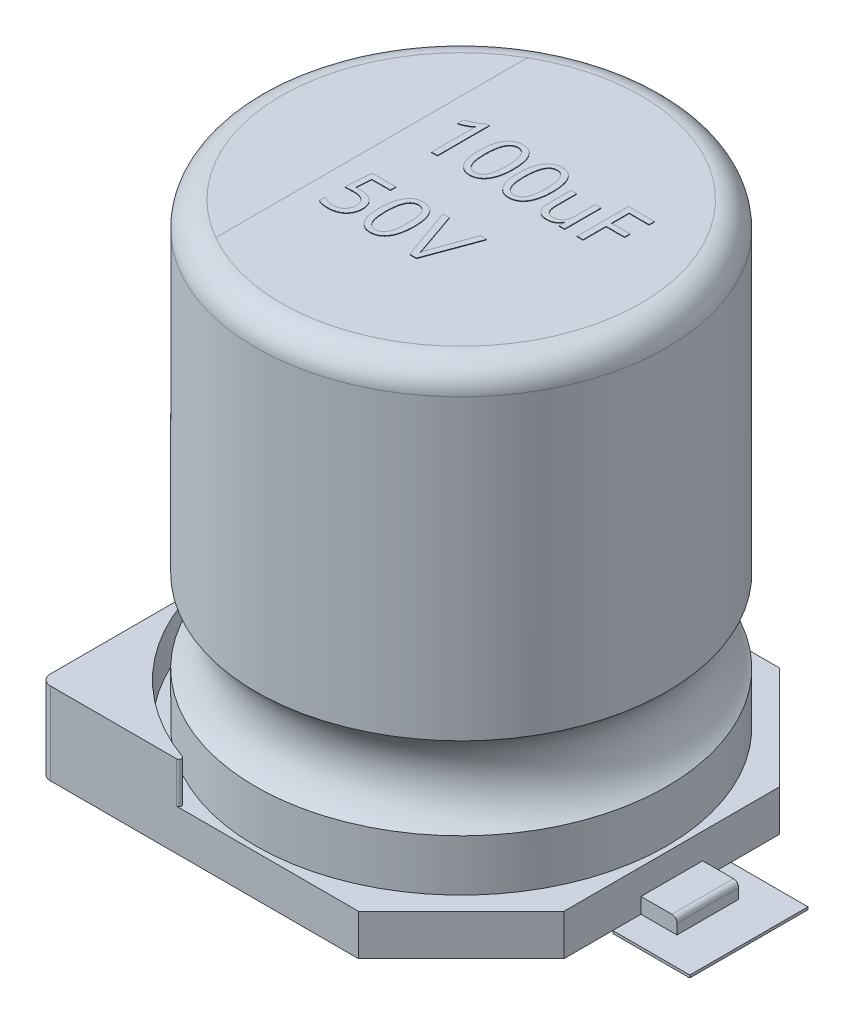
from build123d import *

# Parameters (mm, degrees)
SKETCH1_R             = 4
BOSS_EXTRUDE1_DEPTH   = 8.9
FILLET1_R             = 0.5
SKETCH3_W             = 8.2
SKETCH3_H             = 8.2
BOSS_EXTRUDE2_DEPTH   = 0.8
CHAMFER1_SIZE         = 2
BOSS_EXTRUDE3_DEPTH   = 0.8
FILLET2_R             = 0.05
SKETCH5_W             = 1.2
SKETCH5_H             = 0.3
BOSS_EXTRUDE4_DEPTH   = 0.7
FILLET3_R             = 0.1
FILLET4_R             = 0.2
BOSS_EXTRUDE5_DEPTH   = 0.01
SKETCH8_W             = 1.5
SKETCH8_H             = 2.3
BOSS_EXTRUDE6_DEPTH   = 0.05
BOSS_EXTRUDE6_2_DEPTH = 0.05


with BuildPart() as part:
    # Sketch1 → Boss-Extrude1 (new body)
    with BuildSketch(Plane(origin=(0, 0, 0), x_dir=(1, 0, 0), z_dir=(0, 1, 0))):
        with Locations(Location((0, 0, 0), (0, 0, 270))):
            Circle(SKETCH1_R)
    extrude(amount=BOSS_EXTRUDE1_DEPTH)

    # Sketch2 → Cut-Revolve1 (revolve, cut)
    with BuildSketch(Plane.XY, mode=Mode.PRIVATE) as cut_revolve1_sk:
        with BuildLine():
            Line((-4, 2.6), (-4, 1))
            ThreePointArc((-4, 1), (-3.6, 1.8), (-4, 2.6))
        make_face()
    revolve(cut_revolve1_sk.sketch.rotate(Axis((0, 0, 0), (0, 1, 0)), 270), axis=Axis((0, 0, 0), (0, 1, 0)), mode=Mode.SUBTRACT)

    # Fillet1
    fillet1_edges = [part.edges().sort_by_distance(p)[0] for p in [
        (0, 8.9, -4),
    ]]
    fillet(fillet1_edges, radius=FILLET1_R)

    # Sketch7 → Boss-Extrude5 (add)
    with BuildSketch(Plane(origin=(0, 8.9, 0), x_dir=(1, 0, 0), z_dir=(0, 1, 0))):
        with BuildLine():
            Line((-0.963431723, 0.500188603), (-1.07732975, 0.500188603))
            Line((-1.07732975, 0.500188603), (-1.07732975, 1.355040577))
            add(Edge.make_bspline(
                [(-1.07732975, 1.355040577), (-1.079777093, 1.352756928), (-1.085034792, 1.3478509), (-1.09387705, 1.340498161), (-1.104208441, 1.332640753), (-1.12049976, 1.321512017), (-1.14335142, 1.307312876), (-1.173085751, 1.290498318), (-1.20548104, 1.274747136), (-1.239040454, 1.259578397), (-1.273144639, 1.246529775), (-1.296298393, 1.240145156), (-1.307592907, 1.237030708)],
                knots=[0, 0, 0, 0, 0.385015468, 0.827139693, 1.322250538, 1.877706807, 3.096125656, 4.416274777, 5.805430079, 7.238282366, 8.652820666, 10, 10, 10, 10], degree=3))
            Line((-1.307592907, 1.237030708), (-1.307592907, 1.352162287))
            add(Edge.make_bspline(
                [(-1.307592907, 1.352162287), (-1.294653334, 1.35610978), (-1.267783898, 1.364306875), (-1.227473316, 1.380221553), (-1.186459456, 1.398993626), (-1.14575269, 1.419805536), (-1.106604769, 1.442327949), (-1.069663837, 1.465477943), (-1.036198144, 1.488813595), (-1.016101286, 1.505474617), (-1.006606065, 1.513346498)],
                knots=[0, 0, 0, 0, 0.94458981, 1.961470684, 3.023913207, 4.09427277, 5.153432408, 6.177318749, 7.138832524, 8, 8, 8, 8], degree=3))
            Line((-1.006606065, 1.513346498), (-0.963431723, 1.513346498))
            Line((-0.963431723, 1.513346498), (-0.963431723, 0.500188603))
        make_face()
        with BuildLine():
            add(Edge.make_bspline(
                [(0.005112685, 1.004711629), (0.004826131, 0.984557566), (0.004268968, 0.945370772), (0.00026028, 0.888304877), (-0.00697127, 0.834774088), (-0.01670279, 0.78474756), (-0.029197763, 0.738431643), (-0.044185511, 0.695758481), (-0.061768763, 0.65682236), (-0.081983566, 0.621736309), (-0.104311728, 0.590281443), (-0.129707187, 0.563262978), (-0.157079658, 0.539685765), (-0.187165811, 0.520517467), (-0.219425585, 0.505217818), (-0.254139435, 0.495007822), (-0.29072768, 0.488007663), (-0.315919286, 0.487360705), (-0.328768894, 0.487030708)],
                knots=[0, 0, 0, 0, 1.398980466, 2.720124312, 3.96812368, 5.146432578, 6.255415985, 7.295087503, 8.282879546, 9.216336252, 10.102253837, 10.953825877, 11.784043498, 12.603506409, 13.42284504, 14.253498671, 15.109153359, 16, 16, 16, 16], degree=3))
            add(Edge.make_bspline(
                [(-0.328768894, 0.487030708), (-0.340926926, 0.487403858), (-0.36472116, 0.488134142), (-0.399403608, 0.494513325), (-0.432131855, 0.504747043), (-0.462749696, 0.519260787), (-0.491170149, 0.537718507), (-0.517128174, 0.560078852), (-0.540797909, 0.586154425), (-0.562204288, 0.615858168), (-0.581056959, 0.649361911), (-0.597559877, 0.686395783), (-0.611358843, 0.727057537), (-0.623154052, 0.771117384), (-0.632024842, 0.818768253), (-0.638552103, 0.869693802), (-0.642510507, 0.923988105), (-0.642912284, 0.961256343), (-0.643119223, 0.980451761)],
                knots=[0, 0, 0, 0, 0.888155269, 1.738190458, 2.568434008, 3.38864091, 4.207101744, 5.03849325, 5.886044594, 6.7759361, 7.709272942, 8.69152049, 9.735599895, 10.845083744, 12.023162705, 13.27590253, 14.596923554, 16, 16, 16, 16], degree=3))
            add(Edge.make_bspline(
                [(-0.643119223, 0.980451761), (-0.642843557, 1.001497645), (-0.642307836, 1.042397677), (-0.638162264, 1.101825233), (-0.631477783, 1.157428823), (-0.622151233, 1.20925434), (-0.609844107, 1.257126333), (-0.595126484, 1.301093022), (-0.577891285, 1.341086758), (-0.557950963, 1.376997022), (-0.535517212, 1.40900922), (-0.510275956, 1.436746934), (-0.482599403, 1.460461121), (-0.452195954, 1.479788402), (-0.419394292, 1.49483533), (-0.384192765, 1.505504416), (-0.346852143, 1.512337738), (-0.321123895, 1.513005818), (-0.308004092, 1.513346498)],
                knots=[0, 0, 0, 0, 1.426258677, 2.771754592, 4.035124818, 5.220331935, 6.337825632, 7.382114204, 8.359741748, 9.284994213, 10.161296122, 11.002979272, 11.820109764, 12.624106341, 13.436709906, 14.257961594, 15.111668944, 16, 16, 16, 16], degree=3))
            add(Edge.make_bspline(
                [(-0.308004092, 1.513346498), (-0.295368868, 1.512959369), (-0.270705783, 1.512203721), (-0.23495184, 1.506094994), (-0.201540462, 1.496387059), (-0.170760666, 1.482139609), (-0.14236875, 1.464156343), (-0.116378867, 1.442121729), (-0.09317833, 1.415950319), (-0.072122691, 1.3860259), (-0.054102459, 1.351883719), (-0.03785807, 1.31408476), (-0.024755916, 1.272056949), (-0.013614383, 1.226276634), (-0.005386797, 1.176431001), (0.000747166, 1.12277945), (0.004461983, 1.065070853), (0.004890986, 1.025276442), (0.005112685, 1.004711629)],
                knots=[0, 0, 0, 0, 0.899241396, 1.755257189, 2.575108327, 3.369931066, 4.161902333, 4.96169813, 5.78762661, 6.645962214, 7.56082504, 8.531597655, 9.571777694, 10.691464586, 11.88443752, 13.166498411, 14.535713275, 16, 16, 16, 16], degree=3))
        make_face()
        with BuildLine():
            add(Edge.make_bspline(
                [(-0.111458039, 0.993198471), (-0.111635005, 1.010469562), (-0.111977861, 1.043930687), (-0.114064832, 1.092507874), (-0.118353658, 1.137667761), (-0.12339049, 1.179587018), (-0.13070288, 1.218050581), (-0.139128469, 1.253280964), (-0.149453536, 1.285169971), (-0.161197046, 1.313719893), (-0.174667974, 1.338955551), (-0.189638832, 1.360931968), (-0.206310236, 1.379614653), (-0.224648836, 1.394887973), (-0.244573932, 1.406866101), (-0.266277141, 1.414960968), (-0.289367294, 1.420441518), (-0.305366891, 1.42097051), (-0.313555079, 1.421241235)],
                knots=[0, 0, 0, 0, 1.581181307, 3.063391078, 4.449305256, 5.73327765, 6.92683892, 8.031533681, 9.047337031, 9.992258722, 10.853979057, 11.661441156, 12.421081853, 13.138403699, 13.838846326, 14.537910874, 15.251739941, 16, 16, 16, 16], degree=3))
            add(Edge.make_bspline(
                [(-0.313555079, 1.421241235), (-0.322149139, 1.420956637), (-0.339019139, 1.420397978), (-0.363407175, 1.415083426), (-0.386204613, 1.406638965), (-0.407231815, 1.394518687), (-0.426456861, 1.378867186), (-0.444102981, 1.359920592), (-0.459894199, 1.337502337), (-0.474045623, 1.311820005), (-0.486699712, 1.28281579), (-0.497086535, 1.250213365), (-0.506460167, 1.214429829), (-0.513622413, 1.175157744), (-0.519677256, 1.132653105), (-0.523608913, 1.086666414), (-0.526124054, 1.037292279), (-0.52640388, 1.003207366), (-0.5265485, 0.985591563)],
                knots=[0, 0, 0, 0, 0.764995805, 1.501674303, 2.212925961, 2.924256282, 3.65393935, 4.414460527, 5.224546987, 6.091227052, 7.023912083, 8.039810551, 9.137474513, 10.318540051, 11.595133009, 12.962565651, 14.430189818, 16, 16, 16, 16], degree=3))
            add(Edge.make_bspline(
                [(-0.5265485, 0.985591563), (-0.526402041, 0.969209241), (-0.526118139, 0.937452912), (-0.523614364, 0.891364271), (-0.519634554, 0.848405362), (-0.513809401, 0.808633363), (-0.506874679, 0.771954437), (-0.497741057, 0.738621381), (-0.487380411, 0.708264032), (-0.475039657, 0.681192385), (-0.461392387, 0.656982181), (-0.445580087, 0.636351776), (-0.428514073, 0.618478865), (-0.409363524, 0.604260881), (-0.388775468, 0.592951387), (-0.366538931, 0.58487104), (-0.342611158, 0.580072872), (-0.326118398, 0.579453407), (-0.317666921, 0.579135971)],
                knots=[0, 0, 0, 0, 1.543513286, 2.992024866, 4.347767877, 5.607075833, 6.778486024, 7.862468221, 8.861099137, 9.797386861, 10.662401359, 11.473455982, 12.240599663, 12.983190345, 13.711379138, 14.446775782, 15.204072658, 16, 16, 16, 16], degree=3))
            add(Edge.make_bspline(
                [(-0.317666921, 0.579135971), (-0.309354713, 0.579462603), (-0.293070777, 0.580102486), (-0.269360779, 0.584815964), (-0.247382033, 0.593201099), (-0.226927748, 0.604593384), (-0.208308613, 0.619420262), (-0.191318052, 0.637397511), (-0.175736559, 0.658496883), (-0.162459537, 0.683184252), (-0.150125444, 0.710733256), (-0.13984854, 0.741627939), (-0.130992629, 0.77569519), (-0.123969588, 0.813015594), (-0.118126249, 0.85347046), (-0.114459312, 0.897202574), (-0.111866128, 0.944099177), (-0.111597053, 0.976472965), (-0.111458039, 0.993198471)],
                knots=[0, 0, 0, 0, 0.775360401, 1.518961016, 2.243373551, 2.96192122, 3.694889719, 4.454670758, 5.264184671, 6.134259122, 7.064577354, 8.077594077, 9.167837551, 10.346585987, 11.618858978, 12.979815247, 14.439659868, 16, 16, 16, 16], degree=3))
        make_face(mode=Mode.SUBTRACT)
        with BuildLine():
            add(Edge.make_bspline(
                [(0.768270579, 1.004711629), (0.767984026, 0.984557566), (0.767426863, 0.945370772), (0.763418175, 0.888304877), (0.756186625, 0.834774088), (0.746455105, 0.78474756), (0.733960132, 0.738431643), (0.718972384, 0.695758481), (0.701389132, 0.65682236), (0.681174329, 0.621736309), (0.658846167, 0.590281443), (0.633450707, 0.563262978), (0.606078237, 0.539685765), (0.575992083, 0.520517467), (0.54373231, 0.505217818), (0.50901846, 0.495007822), (0.472430214, 0.488007663), (0.447238608, 0.487360705), (0.434389, 0.487030708)],
                knots=[0, 0, 0, 0, 1.398980466, 2.720124312, 3.96812368, 5.146432578, 6.255415985, 7.295087503, 8.282879546, 9.216336252, 10.102253837, 10.953825877, 11.784043498, 12.603506409, 13.42284504, 14.253498671, 15.109153359, 16, 16, 16, 16], degree=3))
            add(Edge.make_bspline(
                [(0.434389, 0.487030708), (0.422230969, 0.487403858), (0.398436735, 0.488134142), (0.363754287, 0.494513325), (0.331026039, 0.504747043), (0.300408199, 0.519260787), (0.271987746, 0.537718507), (0.246029721, 0.560078852), (0.222359986, 0.586154425), (0.200953607, 0.615858168), (0.182100935, 0.649361911), (0.165598018, 0.686395783), (0.151799052, 0.727057537), (0.140003843, 0.771117384), (0.131133053, 0.818768253), (0.124605791, 0.869693802), (0.120647388, 0.923988105), (0.120245611, 0.961256343), (0.120038671, 0.980451761)],
                knots=[0, 0, 0, 0, 0.888155269, 1.738190458, 2.568434008, 3.38864091, 4.207101744, 5.03849325, 5.886044594, 6.7759361, 7.709272942, 8.69152049, 9.735599895, 10.845083744, 12.023162705, 13.27590253, 14.596923554, 16, 16, 16, 16], degree=3))
            add(Edge.make_bspline(
                [(0.120038671, 0.980451761), (0.120314337, 1.001497645), (0.120850059, 1.042397677), (0.124995631, 1.101825233), (0.131680111, 1.157428823), (0.141006661, 1.20925434), (0.153313788, 1.257126333), (0.168031411, 1.301093022), (0.18526661, 1.341086758), (0.205206931, 1.376997022), (0.227640682, 1.40900922), (0.252881939, 1.436746934), (0.280558491, 1.460461121), (0.31096194, 1.479788402), (0.343763603, 1.49483533), (0.37896513, 1.505504416), (0.416305751, 1.512337738), (0.442033999, 1.513005818), (0.455153803, 1.513346498)],
                knots=[0, 0, 0, 0, 1.426258677, 2.771754592, 4.035124818, 5.220331935, 6.337825632, 7.382114204, 8.359741748, 9.284994213, 10.161296122, 11.002979272, 11.820109764, 12.624106341, 13.436709906, 14.257961594, 15.111668944, 16, 16, 16, 16], degree=3))
            add(Edge.make_bspline(
                [(0.455153803, 1.513346498), (0.467789027, 1.512959369), (0.492452111, 1.512203721), (0.528206054, 1.506094994), (0.561617433, 1.496387059), (0.592397229, 1.482139609), (0.620789145, 1.464156343), (0.646779028, 1.442121729), (0.669979565, 1.415950319), (0.691035204, 1.3860259), (0.709055435, 1.351883719), (0.725299825, 1.31408476), (0.738401979, 1.272056949), (0.749543511, 1.226276634), (0.757771097, 1.176431001), (0.763905061, 1.12277945), (0.767619878, 1.065070853), (0.768048881, 1.025276442), (0.768270579, 1.004711629)],
                knots=[0, 0, 0, 0, 0.899241396, 1.755257189, 2.575108327, 3.369931066, 4.161902333, 4.96169813, 5.78762661, 6.645962214, 7.56082504, 8.531597655, 9.571777694, 10.691464586, 11.88443752, 13.166498411, 14.535713275, 16, 16, 16, 16], degree=3))
        make_face()
        with BuildLine():
            add(Edge.make_bspline(
                [(0.651699856, 0.993198471), (0.651522889, 1.010469562), (0.651180034, 1.043930687), (0.649093063, 1.092507874), (0.644804237, 1.137667761), (0.639767405, 1.179587018), (0.632455014, 1.218050581), (0.624029426, 1.253280964), (0.613704359, 1.285169971), (0.601960849, 1.313719893), (0.588489921, 1.338955551), (0.573519063, 1.360931968), (0.556847658, 1.379614653), (0.538509059, 1.394887973), (0.518583963, 1.406866101), (0.496880754, 1.414960968), (0.473790601, 1.420441518), (0.457791004, 1.42097051), (0.449602816, 1.421241235)],
                knots=[0, 0, 0, 0, 1.581181307, 3.063391078, 4.449305256, 5.73327765, 6.92683892, 8.031533681, 9.047337031, 9.992258722, 10.853979057, 11.661441156, 12.421081853, 13.138403699, 13.838846326, 14.537910874, 15.251739941, 16, 16, 16, 16], degree=3))
            add(Edge.make_bspline(
                [(0.449602816, 1.421241235), (0.441008756, 1.420956637), (0.424138756, 1.420397978), (0.39975072, 1.415083426), (0.376953282, 1.406638965), (0.35592608, 1.394518687), (0.336701034, 1.378867186), (0.319054913, 1.359920592), (0.303263696, 1.337502337), (0.289112272, 1.311820005), (0.276458182, 1.28281579), (0.26607136, 1.250213365), (0.256697728, 1.214429829), (0.249535481, 1.175157744), (0.243480639, 1.132653105), (0.239548982, 1.086666414), (0.23703384, 1.037292279), (0.236754015, 1.003207366), (0.236609395, 0.985591563)],
                knots=[0, 0, 0, 0, 0.764995805, 1.501674303, 2.212925961, 2.924256282, 3.65393935, 4.414460527, 5.224546987, 6.091227052, 7.023912083, 8.039810551, 9.137474513, 10.318540051, 11.595133009, 12.962565651, 14.430189818, 16, 16, 16, 16], degree=3))
            add(Edge.make_bspline(
                [(0.236609395, 0.985591563), (0.236755854, 0.969209241), (0.237039756, 0.937452912), (0.239543531, 0.891364271), (0.243523341, 0.848405362), (0.249348493, 0.808633363), (0.256283216, 0.771954437), (0.265416837, 0.738621381), (0.275777484, 0.708264032), (0.288118237, 0.681192385), (0.301765507, 0.656982181), (0.317577808, 0.636351776), (0.334643822, 0.618478865), (0.35379437, 0.604260881), (0.374382427, 0.592951387), (0.396618963, 0.58487104), (0.420546736, 0.580072872), (0.437039497, 0.579453407), (0.445490974, 0.579135971)],
                knots=[0, 0, 0, 0, 1.543513286, 2.992024866, 4.347767877, 5.607075833, 6.778486024, 7.862468221, 8.861099137, 9.797386861, 10.662401359, 11.473455982, 12.240599663, 12.983190345, 13.711379138, 14.446775782, 15.204072658, 16, 16, 16, 16], degree=3))
            add(Edge.make_bspline(
                [(0.445490974, 0.579135971), (0.453803181, 0.579462603), (0.470087117, 0.580102486), (0.493797116, 0.584815964), (0.515775862, 0.593201099), (0.536230147, 0.604593384), (0.554849281, 0.619420262), (0.571839842, 0.637397511), (0.587421335, 0.658496883), (0.600698358, 0.683184252), (0.61303245, 0.710733256), (0.623309355, 0.741627939), (0.632165265, 0.77569519), (0.639188306, 0.813015594), (0.645031646, 0.85347046), (0.648698582, 0.897202574), (0.651291767, 0.944099177), (0.651560842, 0.976472965), (0.651699856, 0.993198471)],
                knots=[0, 0, 0, 0, 0.775360401, 1.518961016, 2.243373551, 2.96192122, 3.694889719, 4.454670758, 5.264184671, 6.134259122, 7.064577354, 8.077594077, 9.167837551, 10.346585987, 11.618858978, 12.979815247, 14.439659868, 16, 16, 16, 16], degree=3))
        make_face(mode=Mode.SUBTRACT)
        with BuildLine():
            Line((1.513336369, 0.500188603), (1.399438343, 0.500188603))
            Line((1.399438343, 0.500188603), (1.399438343, 0.612441892))
            Line((1.399438343, 0.612441892), (1.396765645, 0.612441892))
            add(Edge.make_bspline(
                [(1.396765645, 0.612441892), (1.390720663, 0.602460299), (1.378922171, 0.5829784), (1.357224617, 0.557406109), (1.333497285, 0.535340747), (1.30679844, 0.517874984), (1.27796377, 0.503876254), (1.246605155, 0.493991312), (1.212766798, 0.488233325), (1.189414343, 0.487439271), (1.177398869, 0.487030708)],
                knots=[0, 0, 0, 0, 1.050691007, 2.050720406, 3.012962404, 3.962401766, 4.915874185, 5.894932476, 6.916885468, 8, 8, 8, 8], degree=3))
            add(Edge.make_bspline(
                [(1.177398869, 0.487030708), (1.167106673, 0.487257871), (1.147213655, 0.487696936), (1.11834269, 0.491353296), (1.091359331, 0.496789144), (1.066537263, 0.505487129), (1.043447569, 0.515877394), (1.022427463, 0.528850187), (1.003437756, 0.544280218), (0.986572548, 0.56212546), (0.971356904, 0.582119485), (0.958722421, 0.604808693), (0.947754222, 0.629646774), (0.938794621, 0.656780083), (0.931760999, 0.68627913), (0.926955997, 0.718120739), (0.92409119, 0.75232886), (0.923696159, 0.775881872), (0.923492619, 0.78801755)],
                knots=[0, 0, 0, 0, 1.09540131, 2.117219514, 3.094696566, 4.020015321, 4.911365501, 5.786165053, 6.642013186, 7.509079247, 8.394916856, 9.30993597, 10.267157936, 11.282441873, 12.347880503, 13.49236844, 14.707944063, 16, 16, 16, 16], degree=3))
            Line((0.923492619, 0.78801755), (0.923492619, 1.210714919))
            Line((0.923492619, 1.210714919), (1.036568277, 1.210714919))
            Line((1.036568277, 1.210714919), (1.036568277, 0.804053735))
            add(Edge.make_bspline(
                [(1.036568277, 0.804053735), (1.036658129, 0.79500285), (1.03683264, 0.777424219), (1.038994686, 0.751898193), (1.042143232, 0.72804247), (1.046826816, 0.705955212), (1.053044542, 0.68569587), (1.060388214, 0.66715835), (1.068975395, 0.650310847), (1.079241694, 0.635355566), (1.090611126, 0.621958112), (1.103608072, 0.610479502), (1.117877537, 0.600820717), (1.133413594, 0.592673278), (1.150370126, 0.586537416), (1.168663857, 0.582288295), (1.188210634, 0.579518344), (1.201717402, 0.57926565), (1.208648869, 0.579135971)],
                knots=[0, 0, 0, 0, 1.343703186, 2.609740898, 3.801442941, 4.915248641, 5.95827345, 6.944754588, 7.873313373, 8.759642607, 9.632786239, 10.476245362, 11.325882859, 12.18618061, 13.074785555, 13.995503533, 14.971323121, 16, 16, 16, 16], degree=3))
            add(Edge.make_bspline(
                [(1.208648869, 0.579135971), (1.215444264, 0.579340895), (1.228822529, 0.579744332), (1.248382544, 0.582703586), (1.267049545, 0.587339775), (1.284654366, 0.594262065), (1.301392063, 0.602948489), (1.317350699, 0.613434023), (1.332147143, 0.626102121), (1.345940795, 0.640486012), (1.358314303, 0.656498858), (1.369603949, 0.673539607), (1.378805849, 0.692024015), (1.38648315, 0.711539654), (1.39212846, 0.732324927), (1.396555207, 0.754141181), (1.398974255, 0.77727204), (1.39928124, 0.793083669), (1.399438343, 0.801175445)],
                knots=[0, 0, 0, 0, 0.99348202, 1.955893163, 2.886897847, 3.800751478, 4.715209456, 5.640858053, 6.586634716, 7.557773505, 8.550193329, 9.542613152, 10.542143211, 11.563936364, 12.604722674, 13.687744657, 14.816677783, 16, 16, 16, 16], degree=3))
            Line((1.399438343, 0.801175445), (1.399438343, 1.210714919))
            Line((1.399438343, 1.210714919), (1.513336369, 1.210714919))
            Line((1.513336369, 1.210714919), (1.513336369, 0.500188603))
        make_face()
        Polygon((2.261897224, 1.394925445), (1.873328145, 1.394925445), (1.873328145, 1.052820182), (2.232703145, 1.052820182), (2.232703145, 0.947557024), (1.873328145, 0.947557024), (1.873328145, 0.500188603), (1.756757421, 0.500188603), (1.756757421, 1.500188603), (2.261897224, 1.500188603), align=None)
        with BuildLine():
            add(Edge.make_bspline(
                [(-0.793612644, -1.127775788), (-0.793960298, -1.139574748), (-0.794642043, -1.162712395), (-0.799064628, -1.196669956), (-0.807223545, -1.228776685), (-0.818031971, -1.259148157), (-0.831964387, -1.287475253), (-0.84837346, -1.313832799), (-0.867512243, -1.338196132), (-0.889334264, -1.360347166), (-0.913582321, -1.380386349), (-0.94053288, -1.397725884), (-0.969631482, -1.413005561), (-1.001266549, -1.425393112), (-1.034752556, -1.435646199), (-1.070265746, -1.44238049), (-1.107502327, -1.4469306), (-1.132962205, -1.447424321), (-1.145997513, -1.447677104)],
                knots=[0, 0, 0, 0, 1.056864167, 2.072500419, 3.059485391, 4.018613275, 4.954681828, 5.881162702, 6.794724112, 7.723560484, 8.661137091, 9.605998599, 10.588833302, 11.59982216, 12.644532083, 13.720683555, 14.833003331, 16, 16, 16, 16], degree=3))
            add(Edge.make_bspline(
                [(-1.145997513, -1.447677104), (-1.157169676, -1.44755688), (-1.178844942, -1.447323631), (-1.210217715, -1.445589255), (-1.239346016, -1.442162006), (-1.266312612, -1.438066715), (-1.291036625, -1.432285861), (-1.313517302, -1.425324282), (-1.333853616, -1.417259251), (-1.346100363, -1.410454138), (-1.352000802, -1.407175459)],
                knots=[0, 0, 0, 0, 1.263126396, 2.450608766, 3.550077914, 4.578015321, 5.532741343, 6.41739748, 7.237507678, 8, 8, 8, 8], degree=3))
            Line((-1.352000802, -1.407175459), (-1.352000802, -1.289782367))
            add(Edge.make_bspline(
                [(-1.352000802, -1.289782367), (-1.343644519, -1.295047632), (-1.327115968, -1.305462213), (-1.301398701, -1.318689721), (-1.275672137, -1.330073303), (-1.249798347, -1.339444348), (-1.223733025, -1.346605094), (-1.1974887, -1.351776104), (-1.171090993, -1.354979568), (-1.153407625, -1.355374304), (-1.144558368, -1.35557184)],
                knots=[0, 0, 0, 0, 1.073575538, 2.123509434, 3.141212585, 4.131255582, 5.1129617, 6.077547705, 7.037950563, 8, 8, 8, 8], degree=3))
            add(Edge.make_bspline(
                [(-1.144558368, -1.35557184), (-1.13577573, -1.355388981), (-1.118565534, -1.355030654), (-1.09348191, -1.351802344), (-1.069600723, -1.347029456), (-1.047197078, -1.339744061), (-1.026294475, -1.330749682), (-1.00693468, -1.320167604), (-0.989181315, -1.308039635), (-0.973029778, -1.29419492), (-0.958648025, -1.278678747), (-0.94576485, -1.261858724), (-0.93509558, -1.243311522), (-0.926051079, -1.223573267), (-0.918714709, -1.20255171), (-0.914035937, -1.180358364), (-0.910707996, -1.157275006), (-0.910360819, -1.141563111), (-0.910183368, -1.133532367)],
                knots=[0, 0, 0, 0, 1.158660806, 2.270477318, 3.333079092, 4.368579658, 5.373363954, 6.332745853, 7.27608927, 8.206156569, 9.134110276, 10.063957633, 10.99630925, 11.951503368, 12.926911662, 13.927616427, 14.940752784, 16, 16, 16, 16], degree=3))
            add(Edge.make_bspline(
                [(-0.910183368, -1.133532367), (-0.910372696, -1.125504516), (-0.91074311, -1.109798279), (-0.913878157, -1.086857782), (-0.919040275, -1.065263813), (-0.925899626, -1.044864207), (-0.935384798, -1.026114831), (-0.9463914, -1.008384945), (-0.960003861, -0.992409341), (-0.97515884, -0.977427808), (-0.992551618, -0.964366436), (-1.011647661, -0.952710772), (-1.032630564, -0.942803068), (-1.055603774, -0.9351487), (-1.080270122, -0.928920598), (-1.106733846, -0.924473626), (-1.135111939, -0.921743454), (-1.154625896, -0.921491479), (-1.164706394, -0.921361314)],
                knots=[0, 0, 0, 0, 1.024220939, 2.003855773, 2.947861307, 3.855091956, 4.742976808, 5.623725423, 6.511739495, 7.414744547, 8.338353125, 9.280330718, 10.266270024, 11.292393647, 12.365736532, 13.510265708, 14.713855882, 16, 16, 16, 16], degree=3))
            add(Edge.make_bspline(
                [(-1.164706394, -0.921361314), (-1.171560192, -0.921394443), (-1.185681562, -0.921462702), (-1.207193389, -0.922254008), (-1.229272396, -0.922665261), (-1.25139504, -0.923887785), (-1.27327405, -0.924724478), (-1.294443985, -0.926244892), (-1.314396907, -0.92779629), (-1.327195143, -0.929147098), (-1.333291921, -0.92979059)],
                knots=[0, 0, 0, 0, 0.974070636, 2.006947305, 3.059296761, 4.112367188, 5.155707916, 6.170982707, 7.128699404, 8, 8, 8, 8], degree=3))
            Line((-1.333291921, -0.92979059), (-1.299369223, -0.434519209))
            Line((-1.299369223, -0.434519209), (-0.839254092, -0.434519209))
            Line((-0.839254092, -0.434519209), (-0.839254092, -0.539782367))
            Line((-0.839254092, -0.539782367), (-1.200890605, -0.539782367))
            Line((-1.200890605, -0.539782367), (-1.221038631, -0.832751117))
            add(Edge.make_bspline(
                [(-1.221038631, -0.832751117), (-1.213433803, -0.832230981), (-1.197753352, -0.831158508), (-1.174165049, -0.830322134), (-1.151213288, -0.829335855), (-1.13633566, -0.829281563), (-1.129344552, -0.829256051)],
                knots=[0, 0, 0, 0, 0.996597619, 2.054892104, 3.085979286, 4, 4, 4, 4], degree=3))
            add(Edge.make_bspline(
                [(-1.129344552, -0.829256051), (-1.116519915, -0.829471408), (-1.091424837, -0.829892817), (-1.054899457, -0.83379702), (-1.020478392, -0.840447124), (-0.98815701, -0.849354217), (-0.958105906, -0.860993658), (-0.930105297, -0.874409082), (-0.904774709, -0.890581171), (-0.881781042, -0.908719161), (-0.861256526, -0.929021564), (-0.843194455, -0.95146848), (-0.828236963, -0.976424175), (-0.815624804, -1.003198072), (-0.805826391, -1.031899989), (-0.798506648, -1.0622926), (-0.794472337, -1.094497952), (-0.793903264, -1.116526179), (-0.793612644, -1.127775788)],
                knots=[0, 0, 0, 0, 1.209722839, 2.367169476, 3.460249484, 4.51448871, 5.52555128, 6.497162283, 7.438882481, 8.354766373, 9.255461188, 10.15719975, 11.065382765, 11.993869493, 12.944690782, 13.921729643, 14.938646801, 16, 16, 16, 16], degree=3))
        make_face()
        with BuildLine():
            add(Edge.make_bspline(
                [(0.005112685, -0.929996183), (0.004826131, -0.950150246), (0.004268968, -0.98933704), (0.00026028, -1.046402935), (-0.00697127, -1.099933724), (-0.01670279, -1.149960252), (-0.029197763, -1.196276169), (-0.044185511, -1.238949331), (-0.061768763, -1.277885452), (-0.081983566, -1.312971503), (-0.104311728, -1.344426369), (-0.129707187, -1.371444834), (-0.157079658, -1.395022046), (-0.187165811, -1.414190345), (-0.219425585, -1.429489994), (-0.254139435, -1.43969999), (-0.29072768, -1.446700149), (-0.315919286, -1.447347107), (-0.328768894, -1.447677104)],
                knots=[0, 0, 0, 0, 1.398980466, 2.720124312, 3.96812368, 5.146432578, 6.255415985, 7.295087503, 8.282879546, 9.216336252, 10.102253837, 10.953825877, 11.784043498, 12.603506409, 13.42284504, 14.253498671, 15.109153359, 16, 16, 16, 16], degree=3))
            add(Edge.make_bspline(
                [(-0.328768894, -1.447677104), (-0.340926926, -1.447303954), (-0.36472116, -1.44657367), (-0.399403608, -1.440194487), (-0.432131855, -1.429960769), (-0.462749696, -1.415447025), (-0.491170149, -1.396989305), (-0.517128174, -1.37462896), (-0.540797909, -1.348553387), (-0.562204288, -1.318849644), (-0.581056959, -1.285345901), (-0.597559877, -1.248312029), (-0.611358843, -1.207650274), (-0.623154052, -1.163590428), (-0.632024842, -1.115939559), (-0.638552103, -1.06501401), (-0.642510507, -1.010719707), (-0.642912284, -0.973451468), (-0.643119223, -0.954256051)],
                knots=[0, 0, 0, 0, 0.888155269, 1.738190458, 2.568434008, 3.38864091, 4.207101744, 5.03849325, 5.886044594, 6.7759361, 7.709272942, 8.69152049, 9.735599895, 10.845083744, 12.023162705, 13.27590253, 14.596923554, 16, 16, 16, 16], degree=3))
            add(Edge.make_bspline(
                [(-0.643119223, -0.954256051), (-0.642843557, -0.933210167), (-0.642307836, -0.892310135), (-0.638162264, -0.832882579), (-0.631477783, -0.777278988), (-0.622151233, -0.725453472), (-0.609844107, -0.677581479), (-0.595126484, -0.63361479), (-0.577891285, -0.593621054), (-0.557950963, -0.55771079), (-0.535517212, -0.525698592), (-0.510275956, -0.497960878), (-0.482599403, -0.47424669), (-0.452195954, -0.45491941), (-0.419394292, -0.439872482), (-0.384192765, -0.429203396), (-0.346852143, -0.422370074), (-0.321123895, -0.421701993), (-0.308004092, -0.421361314)],
                knots=[0, 0, 0, 0, 1.426258677, 2.771754592, 4.035124818, 5.220331935, 6.337825632, 7.382114204, 8.359741748, 9.284994213, 10.161296122, 11.002979272, 11.820109764, 12.624106341, 13.436709906, 14.257961594, 15.111668944, 16, 16, 16, 16], degree=3))
            add(Edge.make_bspline(
                [(-0.308004092, -0.421361314), (-0.295368868, -0.421748443), (-0.270705783, -0.422504091), (-0.23495184, -0.428612818), (-0.201540462, -0.438320753), (-0.170760666, -0.452568203), (-0.14236875, -0.470551469), (-0.116378867, -0.492586082), (-0.09317833, -0.518757492), (-0.072122691, -0.548681912), (-0.054102459, -0.582824092), (-0.03785807, -0.620623051), (-0.024755916, -0.662650863), (-0.013614383, -0.708431178), (-0.005386797, -0.75827681), (0.000747166, -0.811928362), (0.004461983, -0.869636959), (0.004890986, -0.90943137), (0.005112685, -0.929996183)],
                knots=[0, 0, 0, 0, 0.899241396, 1.755257189, 2.575108327, 3.369931066, 4.161902333, 4.96169813, 5.78762661, 6.645962214, 7.56082504, 8.531597655, 9.571777694, 10.691464586, 11.88443752, 13.166498411, 14.535713275, 16, 16, 16, 16], degree=3))
        make_face()
        with BuildLine():
            add(Edge.make_bspline(
                [(-0.111458039, -0.94150934), (-0.111635005, -0.92423825), (-0.111977861, -0.890777124), (-0.114064832, -0.842199937), (-0.118353658, -0.797040051), (-0.12339049, -0.755120794), (-0.13070288, -0.716657231), (-0.139128469, -0.681426848), (-0.149453536, -0.649537841), (-0.161197046, -0.620987919), (-0.174667974, -0.595752261), (-0.189638832, -0.573775843), (-0.206310236, -0.555093158), (-0.224648836, -0.539819839), (-0.244573932, -0.527841711), (-0.266277141, -0.519746844), (-0.289367294, -0.514266294), (-0.305366891, -0.513737302), (-0.313555079, -0.513466577)],
                knots=[0, 0, 0, 0, 1.581181307, 3.063391078, 4.449305256, 5.73327765, 6.92683892, 8.031533681, 9.047337031, 9.992258722, 10.853979057, 11.661441156, 12.421081853, 13.138403699, 13.838846326, 14.537910874, 15.251739941, 16, 16, 16, 16], degree=3))
            add(Edge.make_bspline(
                [(-0.313555079, -0.513466577), (-0.322149139, -0.513751174), (-0.339019139, -0.514309834), (-0.363407175, -0.519624386), (-0.386204613, -0.528068847), (-0.407231815, -0.540189125), (-0.426456861, -0.555840626), (-0.444102981, -0.57478722), (-0.459894199, -0.597205475), (-0.474045623, -0.622887807), (-0.486699712, -0.651892022), (-0.497086535, -0.684494447), (-0.506460167, -0.720277983), (-0.513622413, -0.759550068), (-0.519677256, -0.802054707), (-0.523608913, -0.848041398), (-0.526124054, -0.897415533), (-0.52640388, -0.931500446), (-0.5265485, -0.949116248)],
                knots=[0, 0, 0, 0, 0.764995805, 1.501674303, 2.212925961, 2.924256282, 3.65393935, 4.414460527, 5.224546987, 6.091227052, 7.023912083, 8.039810551, 9.137474513, 10.318540051, 11.595133009, 12.962565651, 14.430189818, 16, 16, 16, 16], degree=3))
            add(Edge.make_bspline(
                [(-0.5265485, -0.949116248), (-0.526402041, -0.965498571), (-0.526118139, -0.9972549), (-0.523614364, -1.043343541), (-0.519634554, -1.08630245), (-0.513809401, -1.126074449), (-0.506874679, -1.162753375), (-0.497741057, -1.196086431), (-0.487380411, -1.22644378), (-0.475039657, -1.253515427), (-0.461392387, -1.277725631), (-0.445580087, -1.298356036), (-0.428514073, -1.316228946), (-0.409363524, -1.330446931), (-0.388775468, -1.341756424), (-0.366538931, -1.349836772), (-0.342611158, -1.35463494), (-0.326118398, -1.355254405), (-0.317666921, -1.35557184)],
                knots=[0, 0, 0, 0, 1.543513286, 2.992024866, 4.347767877, 5.607075833, 6.778486024, 7.862468221, 8.861099137, 9.797386861, 10.662401359, 11.473455982, 12.240599663, 12.983190345, 13.711379138, 14.446775782, 15.204072658, 16, 16, 16, 16], degree=3))
            add(Edge.make_bspline(
                [(-0.317666921, -1.35557184), (-0.309354713, -1.355245209), (-0.293070777, -1.354605326), (-0.269360779, -1.349891848), (-0.247382033, -1.341506713), (-0.226927748, -1.330114428), (-0.208308613, -1.31528755), (-0.191318052, -1.297310301), (-0.175736559, -1.276210929), (-0.162459537, -1.25152356), (-0.150125444, -1.223974556), (-0.13984854, -1.193079873), (-0.130992629, -1.159012622), (-0.123969588, -1.121692217), (-0.118126249, -1.081237352), (-0.114459312, -1.037505238), (-0.111866128, -0.990608635), (-0.111597053, -0.958234847), (-0.111458039, -0.94150934)],
                knots=[0, 0, 0, 0, 0.775360401, 1.518961016, 2.243373551, 2.96192122, 3.694889719, 4.454670758, 5.264184671, 6.134259122, 7.064577354, 8.077594077, 9.167837551, 10.346585987, 11.618858978, 12.979815247, 14.439659868, 16, 16, 16, 16], degree=3))
        make_face(mode=Mode.SUBTRACT)
        with BuildLine():
            Line((0.93048275, -0.434519209), (0.562061698, -1.434519209))
            Line((0.562061698, -1.434519209), (0.433772224, -1.434519209))
            Line((0.433772224, -1.434519209), (0.072958079, -0.434519209))
            Line((0.072958079, -0.434519209), (0.202686698, -0.434519209))
            Line((0.202686698, -0.434519209), (0.478180119, -1.227282367))
            add(Edge.make_bspline(
                [(0.478180119, -1.227282367), (0.480292487, -1.233912657), (0.48464027, -1.247559459), (0.490253492, -1.26899756), (0.494618629, -1.291975053), (0.497072805, -1.307798624), (0.498328145, -1.315892564)],
                knots=[0, 0, 0, 0, 0.917522195, 1.888491001, 2.919938635, 4, 4, 4, 4], degree=3))
            Line((0.498328145, -1.315892564), (0.501000843, -1.315892564))
            add(Edge.make_bspline(
                [(0.501000843, -1.315892564), (0.502053286, -1.308743424), (0.504203131, -1.294139758), (0.509683649, -1.272075225), (0.515798621, -1.249046887), (0.521244423, -1.233690261), (0.524027158, -1.225843222)],
                knots=[0, 0, 0, 0, 0.930702889, 1.901162278, 2.927520758, 4, 4, 4, 4], degree=3))
            Line((0.524027158, -1.225843222), (0.804865974, -0.434519209))
            Line((0.804865974, -0.434519209), (0.93048275, -0.434519209))
        make_face()
    extrude(amount=BOSS_EXTRUDE5_DEPTH)


with BuildPart() as body_2:
    # Sketch3 → Boss-Extrude2 (new body)
    with BuildSketch(Plane.XZ):
        Rectangle(SKETCH3_W, SKETCH3_H)
    extrude(amount=BOSS_EXTRUDE2_DEPTH)

    # Chamfer1
    chamfer1_edges = [body_2.edges().sort_by_distance(p)[0] for p in [
        (4.1, -0.4, 4.1),
        (4.1, -0.4, -4.1),
    ]]
    chamfer(chamfer1_edges, length=CHAMFER1_SIZE)

    # Sketch4 → Boss-Extrude3 (add)
    with BuildSketch(Plane(origin=(0, 0, 0), x_dir=(1, 0, 0), z_dir=(0, 1, 0))):
        with BuildLine():
            Line((-1.119151464, -4.1), (-4.1, -4.1))
            Line((-4.1, -4.1), (-4.1, -1.119151464))
            ThreePointArc((-4.1, -1.119151464), (-3.00520382, -3.00520382), (-1.119151464, -4.1))
        make_face()
        with BuildLine():
            Line((-4.1, 4.1), (-1.119151464, 4.1))
            ThreePointArc((-1.119151464, 4.1), (-3.00520382, 3.00520382), (-4.1, 1.119151464))
            Line((-4.1, 1.119151464), (-4.1, 4.1))
        make_face()
    extrude(amount=BOSS_EXTRUDE3_DEPTH)

    # Fillet2
    fillet2_edges = [body_2.edges().sort_by_distance(p)[0] for p in [
        (-4.1, 0.4, -1.119151464),
        (-1.119151464, 0.4, -4.1),
        (-4.1, 0.4, 1.119151464),
        (-1.119151464, 0.4, 4.1),
    ]]
    fillet(fillet2_edges, radius=FILLET2_R)

    # Fillet4
    fillet4_edges = [body_2.edges().sort_by_distance(p)[0] for p in [
        (-4.1, 0, 4.1),
        (-4.1, 0, -4.1),
    ]]
    fillet(fillet4_edges, radius=FILLET4_R)


with BuildPart() as body_3:
    # Sketch5 → Boss-Extrude4 (new body)
    with BuildSketch(Plane.ZY.offset(4.1)):
        with Locations((0, -0.65)):
            Rectangle(SKETCH5_W, SKETCH5_H)
    extrude(amount=BOSS_EXTRUDE4_DEPTH)

    # Fillet3
    fillet3_edges = [body_3.edges().sort_by_distance(p)[0] for p in [
        (-4.8, -0.5, 0),
    ]]
    fillet(fillet3_edges, radius=FILLET3_R)


with BuildPart() as body_4:
    # Mirror3: mirrored copy
    add(body_3.part.mirror(Plane(origin=(0, 0, 0), x_dir=(0, 0, 1), z_dir=(1, 0, 0))))


with BuildPart() as body_5:
    # Sketch8 → Boss-Extrude6 (new body)
    with BuildSketch(Plane.XZ.offset(0.8)):
        with Locations((-4.85, 0)):
            Rectangle(SKETCH8_W, SKETCH8_H)
    extrude(amount=BOSS_EXTRUDE6_DEPTH)


with BuildPart() as body_6:
    # Sketch8 → Boss-Extrude6 2 (new body)
    with BuildSketch(Plane.XZ.offset(0.8)):
        with Locations((4.85, 0)):
            Rectangle(SKETCH8_W, SKETCH8_H)
    extrude(amount=BOSS_EXTRUDE6_2_DEPTH)


solid = Compound([part.part, body_2.part, body_3.part, body_4.part, body_5.part, body_6.part])
